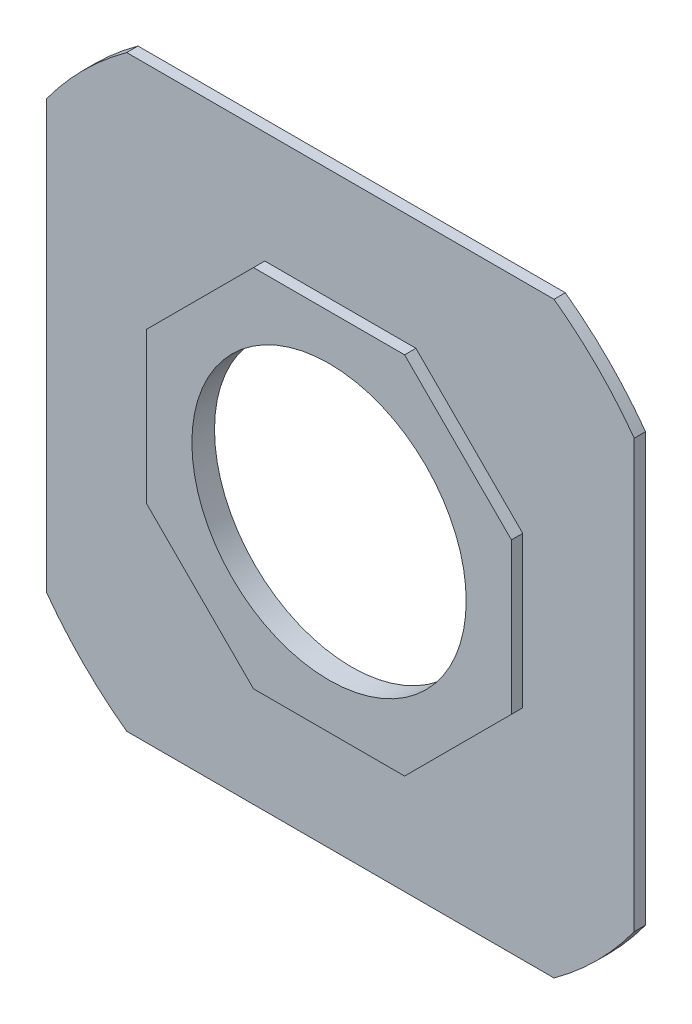
from build123d import *

# Parameters (mm, degrees)
SKETCH1_W           = 203.947710216
SKETCH1_H           = 203.947710216
SKETCH1_R           = 38.5
BOSS_EXTRUDE1_DEPTH = 3.175
SKETCH1_3_R         = 38.5
BOSS_EXTRUDE2_DEPTH = 6.35
SKETCH6_W           = 203.947710216
SKETCH6_H           = 203.947710216
CUT_EXTRUDE1_DEPTH  = 15


with BuildPart() as part:
    # Sketch1 → Boss-Extrude1 (new body)
    with BuildSketch(Plane.XY):
        Rectangle(SKETCH1_W, SKETCH1_H)
        Circle(SKETCH1_R, mode=Mode.SUBTRACT)
    extrude(amount=BOSS_EXTRUDE1_DEPTH)

    # Sketch1_3 → Boss-Extrude2 (add)
    with BuildSketch(Plane.XY):
        Polygon((51.2, 21.207734394), (21.207734394, 51.2), (-21.207734394, 51.2), (-51.2, 21.207734394), (-51.2, -21.207734394), (-21.207734394, -51.2), (21.207734394, -51.2), (51.2, -21.207734394), align=None)
        Circle(SKETCH1_3_R, mode=Mode.SUBTRACT)
    extrude(amount=BOSS_EXTRUDE2_DEPTH)

    # Sketch6 → Cut-Extrude1 (cut)
    with BuildSketch(Plane(origin=(0, 0, 0), x_dir=(-1, 0, 0), z_dir=(0, 0, -1))):
        Rectangle(SKETCH6_W, SKETCH6_H)
        with BuildLine():
            Line((-82.5, -59.981247069), (-82.5, 59.981247069))
            ThreePointArc((-82.5, 59.981247069), (-72.124891681, 72.124891681), (-59.981247069, 82.5))
            Line((-59.981247069, 82.5), (59.981247069, 82.5))
            ThreePointArc((59.981247069, 82.5), (72.124891681, 72.124891681), (82.5, 59.981247069))
            Line((82.5, 59.981247069), (82.5, -59.981247069))
            ThreePointArc((82.5, -59.981247069), (72.124891681, -72.124891681), (59.981247069, -82.5))
            Line((59.981247069, -82.5), (-59.981247069, -82.5))
            ThreePointArc((-59.981247069, -82.5), (-72.124891681, -72.124891681), (-82.5, -59.981247069))
        make_face(mode=Mode.SUBTRACT)
    extrude(amount=-CUT_EXTRUDE1_DEPTH, mode=Mode.SUBTRACT)


solid = part.part
